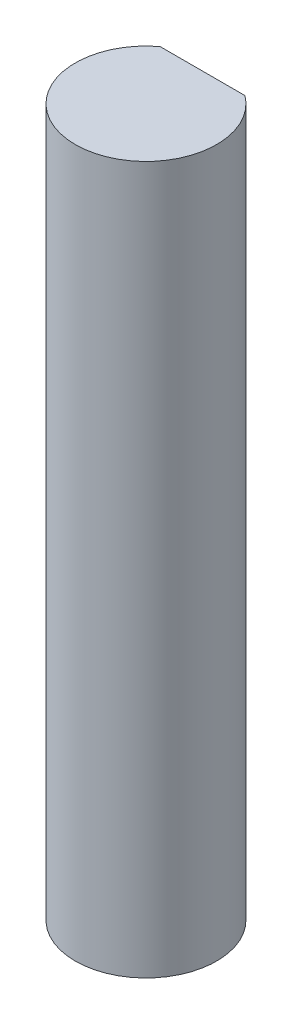
from build123d import *

# Parameters (mm, degrees)
BOSS_EXTRUDE1_DEPTH = 31.75


with BuildPart() as part:
    # Sketch1 → Boss-Extrude1 (new body)
    with BuildSketch(Plane(origin=(0, 0, 0), x_dir=(1, 0, 0), z_dir=(0, 1, 0))):
        with BuildLine():
            Line((-1.905, 2.54), (1.905, 2.54))
            ThreePointArc((1.905, 2.54), (0, -3.175), (-1.905, 2.54))
        make_face()
    extrude(amount=BOSS_EXTRUDE1_DEPTH)


solid = part.part
